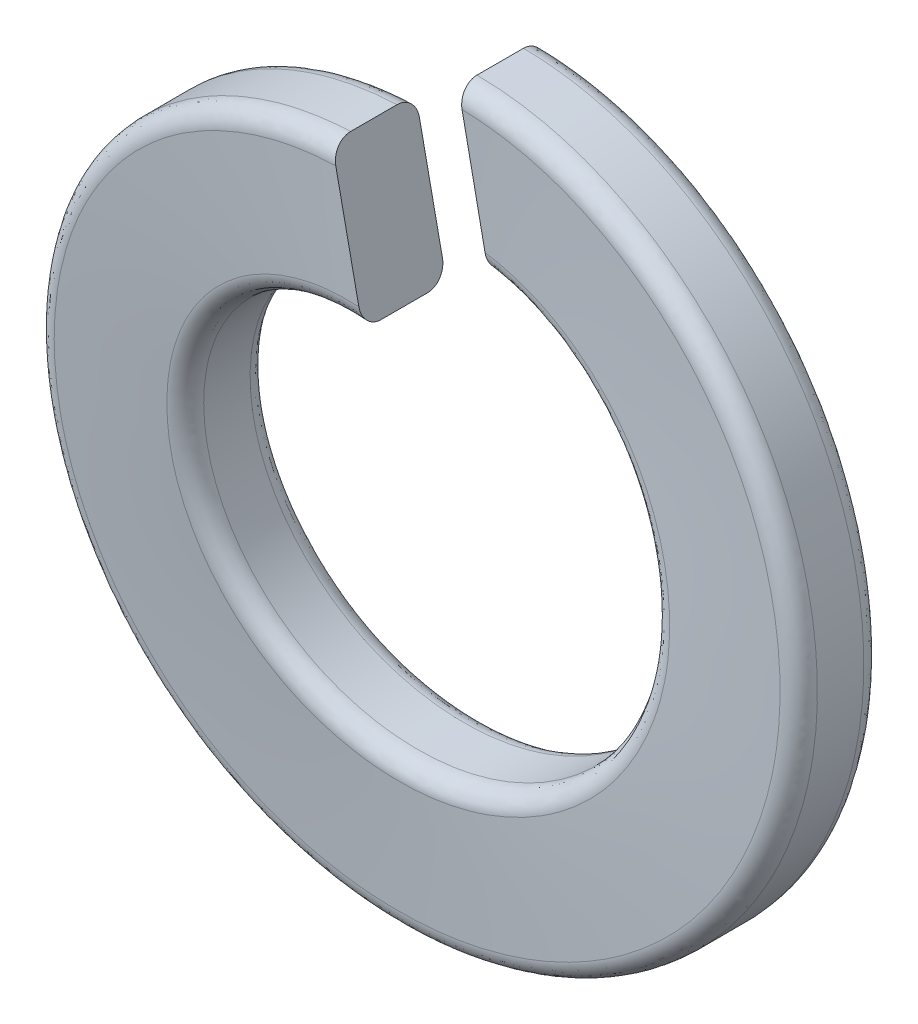
from build123d import *

# Parameters (mm, degrees)
SWEEP1_PITCH       = 1.201201
SWEEP1_HEIGHT      = 1.2
SWEEP1_RADIUS      = 3.8
SWEEP1_START_ANGLE = 85
CUT_EXTRUDE1_DEPTH = 2.05
FILLET1_R          = 0.2


with BuildPart() as part:
    # Sweep1: sweep along a helix
    with BuildLine() as sweep1_path:
        add(Helix(SWEEP1_PITCH, SWEEP1_HEIGHT, SWEEP1_RADIUS, center=(0, 0, 0.6), direction=(0, 0, -1), lefthand=True, mode=Mode.PRIVATE).rotate(Axis((0, 0, 0.6), (0, 0, -1)), SWEEP1_START_ANGLE))
    # Sketch4 → Sweep1 (sweep)
    with BuildSketch(Plane(origin=(0.469922, -0.049692, 0.005065), x_dir=(0.007151, -0.034234, -0.999388), z_dir=(0.978873, 0.20447, 0))):
        Polygon((-1.181321, 3.879066), (-0.281871, 3.910542), (-0.225223, 2.291772), (-1.124673, 2.260297), align=None)
    sweep(path=sweep1_path.line, is_frenet=True)

    # Sketch5 → Cut-Extrude1 (cut, through all)
    with BuildSketch(Plane.XY):
        with BuildLine():
            Line((0, 2.2), (-0.331192, 3.78554))
            ThreePointArc((-0.331192, 3.78554), (-0.248532, 3.791864), (-0.165754, 3.796383))
            Line((-0.165754, 3.796383), (0.169062, 2.193494))
            ThreePointArc((0.169062, 2.193494), (0.084594, 2.198373), (0, 2.2))
        make_face()
    extrude(amount=-CUT_EXTRUDE1_DEPTH, mode=Mode.SUBTRACT)

    # Fillet1
    fillet1_edges = [part.edges().sort_by_distance(p)[0] for p in [
        (0.248532, -3.79186, 0.45357),
        (0.248532, -3.79186, -0.44643),
        (-0.084593, -2.198371, 0.456752),
        (-0.084593, -2.198371, -0.443248),
    ]]
    fillet(fillet1_edges, radius=FILLET1_R)


solid = part.part
